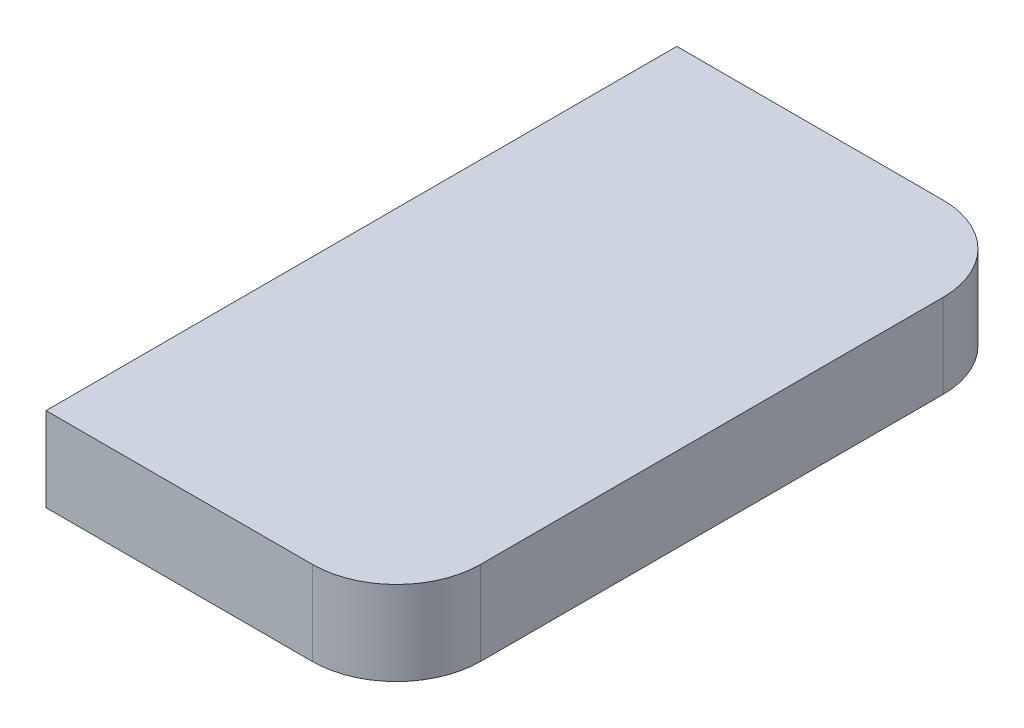
from build123d import *

# Parameters (mm, degrees)
SKETCH1_W           = 100
SKETCH1_H           = 75
BOSS_EXTRUDE1_DEPTH = 10
FILLET1_R           = 10
SKETCH2_W           = 88.511966946
SKETCH2_H           = 129.218884933
CUT_EXTRUDE1_DEPTH  = 11


with BuildPart() as part:
    # Sketch1 → Boss-Extrude1 (new body)
    with BuildSketch(Plane(origin=(0, 0, 0), x_dir=(1, 0, 0), z_dir=(0, 1, 0))):
        with Locations((50, 37.5)):
            Rectangle(SKETCH1_W, SKETCH1_H)
    extrude(amount=BOSS_EXTRUDE1_DEPTH)

    # Fillet1
    fillet1_edges = [part.edges().sort_by_distance(p)[0] for p in [
        (0, 5, -75),
        (100, 5, -75),
        (100, 5, 0),
        (0, 5, 0),
    ]]
    fillet(fillet1_edges, radius=FILLET1_R)

    # Sketch2 → Cut-Extrude1 (cut, through all)
    with BuildSketch(Plane(origin=(0, 10, 0), x_dir=(1, 0, 0), z_dir=(0, 1, 0))):
        with Locations((14.077953322, 38.537528746)):
            Rectangle(SKETCH2_W, SKETCH2_H)
    extrude(amount=-CUT_EXTRUDE1_DEPTH, mode=Mode.SUBTRACT)


solid = part.part
